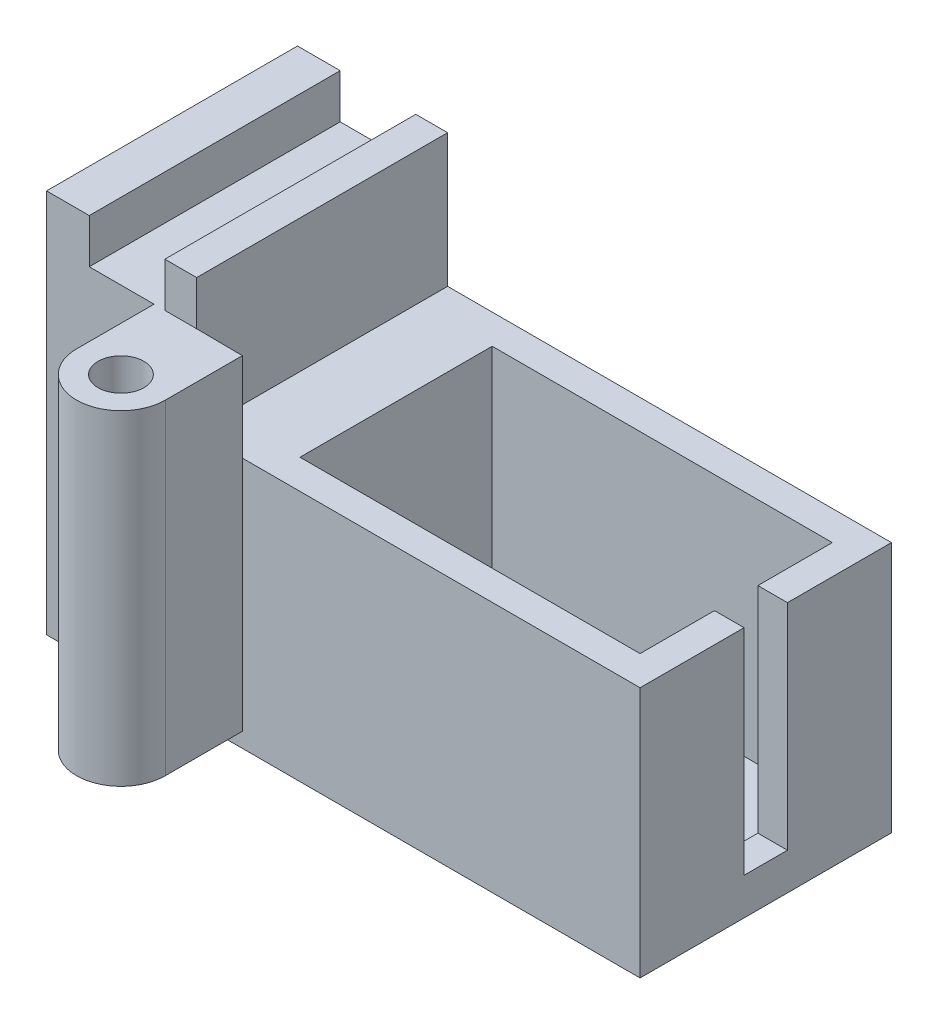
from build123d import *

# Parameters (mm, degrees)
SKETCH1_W                 = 27
SKETCH1_H                 = 17
SKETCH1_W_2               = 23
SKETCH1_H_2               = 13
BOSS_EXTRUDE1_DEPTH       = 1.5
SKETCH1_3_W               = 27
SKETCH1_3_H               = 17
SKETCH1_3_W_2             = 23
SKETCH1_3_H_2             = 13
BOSS_EXTRUDE2_DEPTH       = 17
SKETCH2_W                 = 4.291322887
SKETCH2_H                 = 2.933386364
CUT_EXTRUDE1_DEPTH        = 14.5
SKETCH3_R                 = 1.776145291
CUT_EXTRUDE2_DEPTH        = 14.5
SKETCH4_W                 = 17
SKETCH4_H                 = 17
BOSS_EXTRUDE3_DEPTH       = 5
SKETCH5_W                 = 6.111771398
SKETCH5_H                 = 16.943398975
BOSS_EXTRUDE4_DEPTH       = 23
SKETCH6_R                 = 1.5
BOSS_EXTRUDE9_DEPTH       = 22
SKETCH10_W                = 10.152493364
SKETCH10_H                = 16.970590483
BOSS_EXTRUDE10_DEPTH      = 3
BOSS_EXTRUDE10_DEPTH_BACK = 23
SKETCH8_W                 = 5.111825198
SKETCH8_H                 = 22.20816513
CUT_EXTRUDE4_DEPTH        = 3
CUT_EXTRUDE4_DEPTH_BACK   = 3
SKETCH11_R                = 1.55
CUT_EXTRUDE5_DEPTH        = 31


with BuildPart() as part:
    # Sketch1 → Boss-Extrude1 (new body)
    with BuildSketch(Plane(origin=(0, 0, 0), x_dir=(1, 0, 0), z_dir=(0, 1, 0))):
        Rectangle(SKETCH1_W, SKETCH1_H)
        Rectangle(SKETCH1_W_2, SKETCH1_H_2, mode=Mode.SUBTRACT)
        Rectangle(SKETCH1_W_2, SKETCH1_H_2)
    extrude(amount=BOSS_EXTRUDE1_DEPTH)

    # Sketch1_3 → Boss-Extrude2 (add)
    with BuildSketch(Plane(origin=(0, 0, 0), x_dir=(1, 0, 0), z_dir=(0, 1, 0))):
        Rectangle(SKETCH1_3_W, SKETCH1_3_H)
        Rectangle(SKETCH1_3_W_2, SKETCH1_3_H_2, mode=Mode.SUBTRACT)
    extrude(amount=BOSS_EXTRUDE2_DEPTH)

    # Sketch2 → Cut-Extrude1 (cut)
    with BuildSketch(Plane(origin=(0, 17, 0), x_dir=(1, 0, 0), z_dir=(0, 1, 0))):
        with Locations((12.620499192, 0)):
            Rectangle(SKETCH2_W, SKETCH2_H)
    extrude(amount=-CUT_EXTRUDE1_DEPTH, mode=Mode.SUBTRACT)

    # Sketch3 → Cut-Extrude2 (cut)
    with BuildSketch(Plane(origin=(0, 1.5, 0), x_dir=(1, 0, 0), z_dir=(0, 1, 0))):
        with Locations(Location((-6.765421027, 0, 0), (0, 0, 270))):
            Circle(SKETCH3_R)
    cut_extrude2 = extrude(amount=-CUT_EXTRUDE2_DEPTH, mode=Mode.SUBTRACT)

    # Mirror1: Cut-Extrude2 across plane
    add(cut_extrude2.mirror(Plane(origin=(0, 0, 0), x_dir=(0, 0, 1), z_dir=(1, 0, 0))), mode=Mode.SUBTRACT)

    # Sketch4 → Boss-Extrude3 (add)
    with BuildSketch(Plane.ZY.offset(13.5)):
        with Locations((0, 8.5)):
            Rectangle(SKETCH4_W, SKETCH4_H)
    extrude(amount=BOSS_EXTRUDE3_DEPTH)

    # Sketch5 → Boss-Extrude4 (add)
    with BuildSketch(Plane.XZ):
        with Locations((-21.555885699, -0.028300512)):
            Rectangle(SKETCH5_W, SKETCH5_H)
    extrude(amount=-BOSS_EXTRUDE4_DEPTH)



with BuildPart() as body_2:
    # Sketch6 → Boss-Extrude9 (new body)
    with BuildSketch(Plane(origin=(0, 23, 0), x_dir=(1, 0, 0), z_dir=(0, 1, 0))):
        with BuildLine():
            Line((-19.397979401, -13.709269216), (-19.397979401, -8.443398975))
            Line((-19.397979401, -8.443398975), (-13.397979401, -8.5))
            Line((-13.397979401, -8.5), (-13.397979401, -13.709269216))
            ThreePointArc((-13.397979401, -13.709269216), (-16.397979401, -16.709269216), (-19.397979401, -13.709269216))
        make_face()
        with Locations(Location((-16.397979401, -13.709269216, 0), (0, 0, 180))):
            Circle(SKETCH6_R, mode=Mode.SUBTRACT)
    extrude(amount=-BOSS_EXTRUDE9_DEPTH)


with BuildPart() as part_1:
    add(part.part)

    add(body_2.part)  # Boss-Extrude10 merges body 2
    # Sketch10 → Boss-Extrude10 (add, two sides)
    with BuildSketch(Plane(origin=(0, 23, 0), x_dir=(1, 0, 0), z_dir=(0, 1, 0))) as boss_extrude10_sk:
        with Locations((-21.591786232, 0.014704758)):
            Rectangle(SKETCH10_W, SKETCH10_H)
    extrude(amount=BOSS_EXTRUDE10_DEPTH)
    extrude(boss_extrude10_sk.sketch, amount=-BOSS_EXTRUDE10_DEPTH_BACK)

    # Sketch8 → Cut-Extrude4 (cut, two sides)
    with BuildSketch(Plane(origin=(0, 26, 0), x_dir=(1, 0, 0), z_dir=(0, 1, 0))) as cut_extrude4_sk:
        with Locations((-21.223699311, -0.490089781)):
            Rectangle(SKETCH8_W, SKETCH8_H)
    extrude(amount=CUT_EXTRUDE4_DEPTH, mode=Mode.SUBTRACT)
    extrude(cut_extrude4_sk.sketch, amount=-CUT_EXTRUDE4_DEPTH_BACK, mode=Mode.SUBTRACT)

    # Sketch11 → Cut-Extrude5 (cut)
    with BuildSketch(Plane(origin=(0, 23, 0), x_dir=(1, 0, 0), z_dir=(0, 1, 0))):
        with Locations(Location((-16.397979401, -13.709269216, 0), (0, 0, 180))):
            Circle(SKETCH11_R)
    extrude(amount=-CUT_EXTRUDE5_DEPTH, mode=Mode.SUBTRACT)


solid = part_1.part
